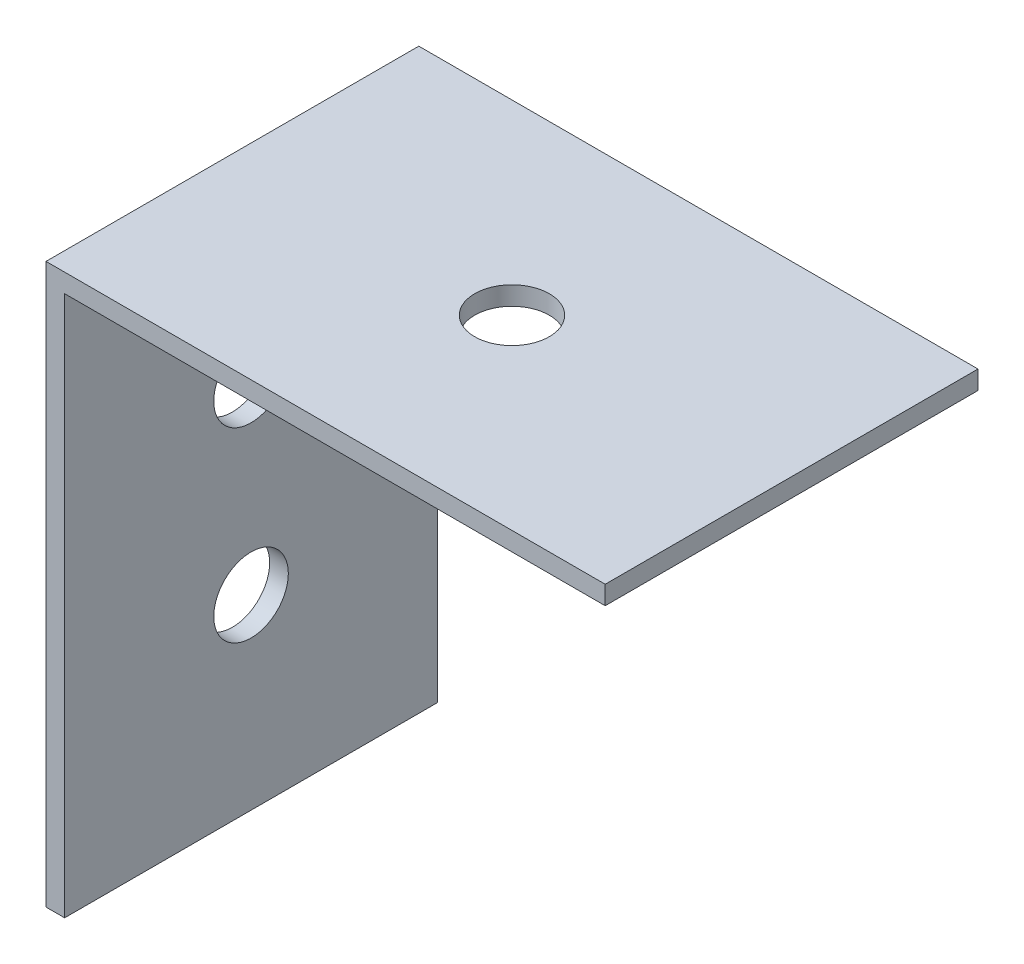
from build123d import *

# Parameters (mm, degrees)
SKETCH2_W           = 20
SKETCH2_H           = 30
SKETCH2_R           = 2
BOSS_EXTRUDE1_DEPTH = 1
SKETCH3_W           = 20
SKETCH3_H           = 1
BOSS_EXTRUDE2_DEPTH = 29
SKETCH4_R           = 2
CUT_EXTRUDE1_DEPTH  = 30


with BuildPart() as part:
    # Sketch2 → Boss-Extrude1 (new body)
    with BuildSketch(Plane(origin=(0, 0, 0), x_dir=(0, 0, -1), z_dir=(1, 0, 0))):
        with Locations((10, 15)):
            Rectangle(SKETCH2_W, SKETCH2_H)
        with Locations((10, 20)):
            Circle(SKETCH2_R, mode=Mode.SUBTRACT)
        with Locations((10, 10)):
            Circle(SKETCH2_R, mode=Mode.SUBTRACT)
    extrude(amount=BOSS_EXTRUDE1_DEPTH)

    # Sketch3 → Boss-Extrude2 (add)
    with BuildSketch(Plane(origin=(1, 0, 0), x_dir=(0, 0, -1), z_dir=(1, 0, 0))):
        with Locations((10, 29.5)):
            Rectangle(SKETCH3_W, SKETCH3_H)
    extrude(amount=BOSS_EXTRUDE2_DEPTH)

    # Sketch4 → Cut-Extrude1 (cut)
    with BuildSketch(Plane(origin=(0, 30, 0), x_dir=(1, 0, 0), z_dir=(0, 1, 0))):
        with Locations((15, 10)):
            Circle(SKETCH4_R)
    extrude(amount=-CUT_EXTRUDE1_DEPTH, mode=Mode.SUBTRACT)


solid = part.part
